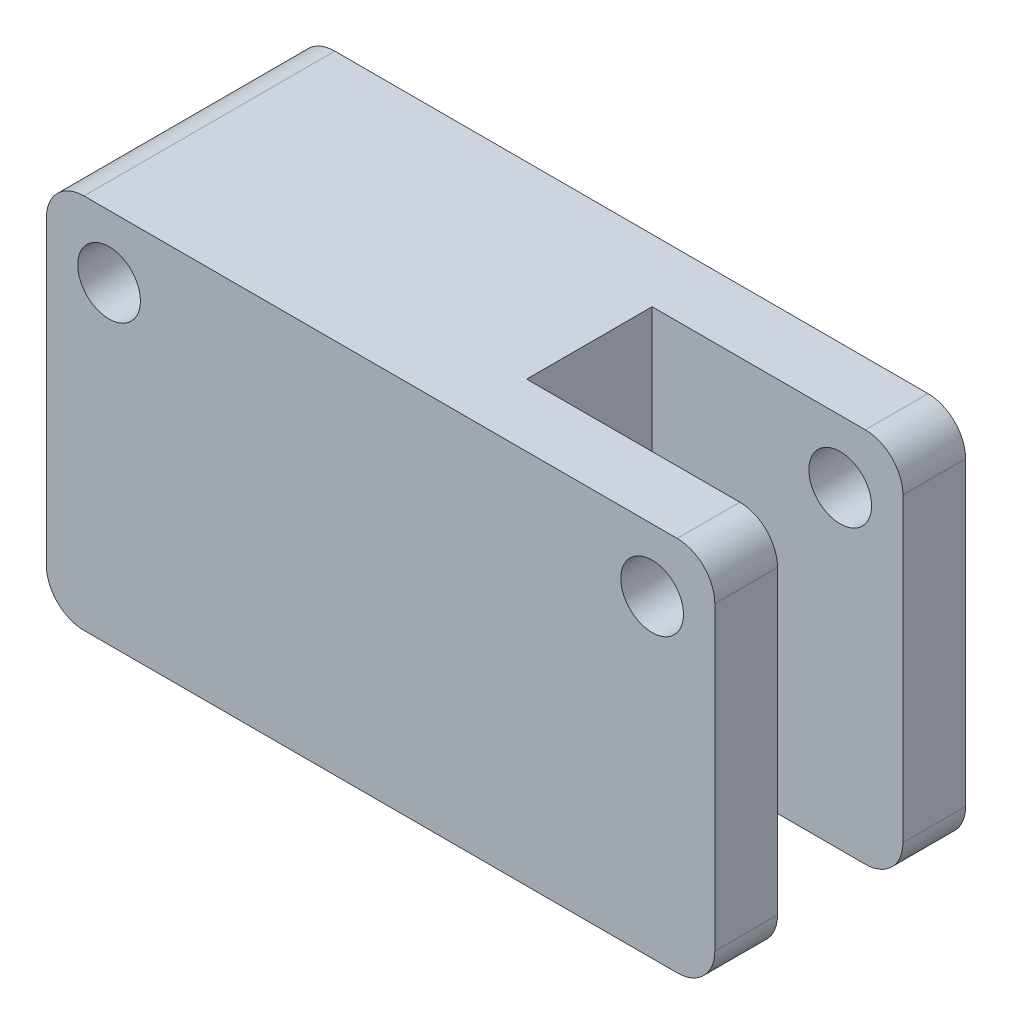
from build123d import *

# Parameters (mm, degrees)
ESQUISSE2_W             = 53.3
ESQUISSE2_H             = 20
BOSS_EXTRU_1_DEPTH      = 15
CONG_1_R                = 3
ESQUISSE4_W             = 20
ESQUISSE4_H             = 10
ENL_V_MAT_EXTRU_1_DEPTH = 62.97491428
ESQUISSE5_R             = 2.5
ENL_V_MAT_EXTRU_2_DEPTH = 59.871809892


with BuildPart() as part:
    # Esquisse2 → Boss.-Extru.1 (new, symmetric)
    with BuildSketch(Plane(origin=(0, 0, 0), x_dir=(1, 0, 0), z_dir=(0, 1, 0))):
        with Locations((26.65, 0)):
            Rectangle(ESQUISSE2_W, ESQUISSE2_H)
    extrude(amount=BOSS_EXTRU_1_DEPTH, both=True)

    # Congé1
    cong_1_edges = [part.edges().sort_by_distance(p)[0] for p in [
        (0, 15, 0),
        (53.3, 15, 0),
        (53.3, -15, 0),
        (0, -15, 0),
    ]]
    fillet(cong_1_edges, radius=CONG_1_R)

    # Esquisse4 → Enlèv. mat.-Extru.1 (cut, through all)
    with BuildSketch(Plane(origin=(0, 15, 0), x_dir=(1, 0, 0), z_dir=(0, 1, 0))):
        with Locations((43.3, 0)):
            Rectangle(ESQUISSE4_W, ESQUISSE4_H)
    extrude(amount=-ENL_V_MAT_EXTRU_1_DEPTH, mode=Mode.SUBTRACT)

    # Esquisse5 → Enlèv. mat.-Extru.2 (cut, through all)
    with BuildSketch(Plane(origin=(0, 0, -10), x_dir=(-1, 0, 0), z_dir=(0, 0, -1))):
        with Locations((-48.3, 10)):
            Circle(ESQUISSE5_R)
        with Locations((-5, 10)):
            Circle(ESQUISSE5_R)
    extrude(amount=-ENL_V_MAT_EXTRU_2_DEPTH, mode=Mode.SUBTRACT)


solid = part.part
